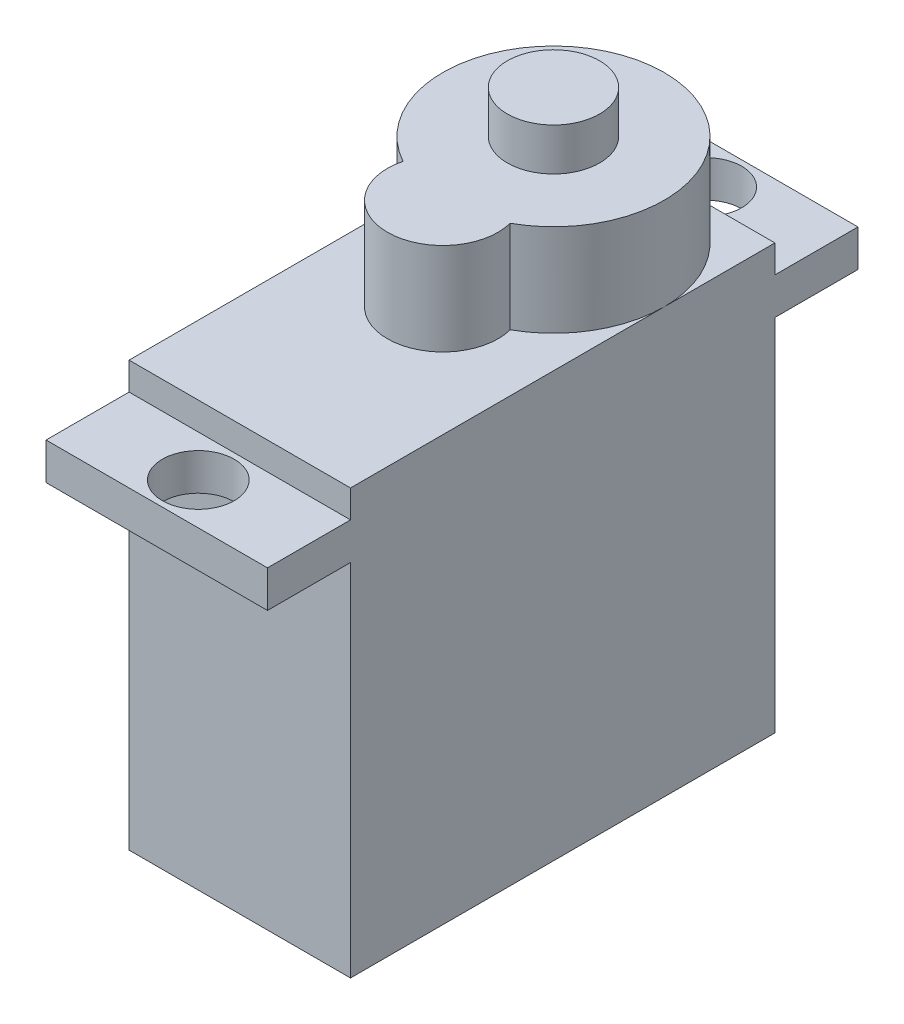
from build123d import *

# Parameters (mm, degrees)
ESQUISSE1_W             = 12
ESQUISSE1_H             = 23
BOSS_EXTRU_1_DEPTH      = 3.5
BOSS_EXTRU_1_DEPTH_BACK = 19.5
ESQUISSE2_W             = 12
ESQUISSE2_H             = 32
BOSS_EXTRU_2_DEPTH      = 2
BOSS_EXTRU_3_DEPTH      = 5
ESQUISSE4_R             = 2.5
BOSS_EXTRU_4_DEPTH      = 2.3
ESQUISSE5_R             = 1.95
ENL_V_MAT_EXTRU_1_DEPTH = 11.8


with BuildPart() as part:
    # Esquisse1 → Boss.-Extru.1 (new body, two sides)
    with BuildSketch(Plane(origin=(0, 0, 0), x_dir=(1, 0, 0), z_dir=(0, 1, 0))) as boss_extru_1_sk:
        with Locations((0, -5.5)):
            Rectangle(ESQUISSE1_W, ESQUISSE1_H)
    extrude(amount=BOSS_EXTRU_1_DEPTH)
    extrude(boss_extru_1_sk.sketch, amount=-BOSS_EXTRU_1_DEPTH_BACK)

    # Esquisse2 → Boss.-Extru.2 (add)
    with BuildSketch(Plane(origin=(0, 0, 0), x_dir=(1, 0, 0), z_dir=(0, 1, 0))):
        with Locations((0, -5.5)):
            Rectangle(ESQUISSE2_W, ESQUISSE2_H)
    extrude(amount=BOSS_EXTRU_2_DEPTH)

    # Esquisse3 → Boss.-Extru.3 (add)
    with BuildSketch(Plane(origin=(0, 3.5, 0), x_dir=(1, 0, 0), z_dir=(0, 1, 0))):
        with BuildLine():
            ThreePointArc((2.90473751, -5.25), (0, 6), (-2.90473751, -5.25))
            ThreePointArc((-2.90473751, -5.25), (0, -9), (2.90473751, -5.25))
        make_face()
    extrude(amount=BOSS_EXTRU_3_DEPTH)

    # Esquisse4 → Boss.-Extru.4 (add)
    with BuildSketch(Plane(origin=(0, 8.5, 0), x_dir=(1, 0, 0), z_dir=(0, 1, 0))):
        Circle(ESQUISSE4_R)
    extrude(amount=BOSS_EXTRU_4_DEPTH)

    # Esquisse5 → Enlèv. mat.-Extru.1 (cut, through all)
    with BuildSketch(Plane(origin=(0, 0, 0), x_dir=(1, 0, 0), z_dir=(0, 1, 0))):
        with Locations((0, -19.25)):
            Circle(ESQUISSE5_R)
        with Locations((0, 8.25)):
            Circle(ESQUISSE5_R)
    extrude(amount=ENL_V_MAT_EXTRU_1_DEPTH, mode=Mode.SUBTRACT)


solid = part.part
